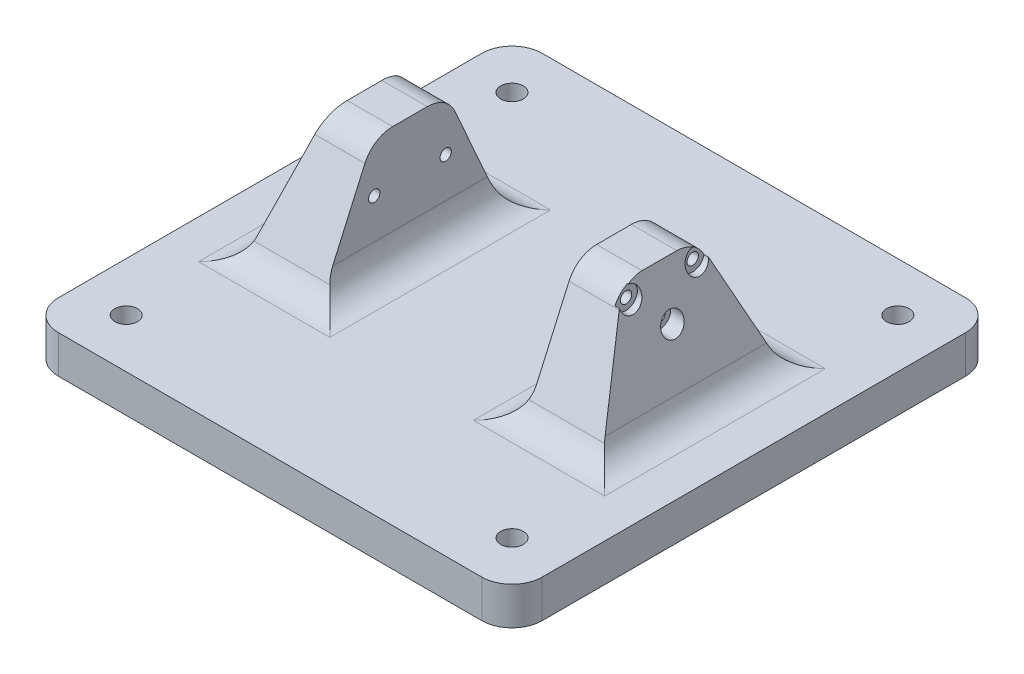
from build123d import *

# Parameters (mm, degrees)
SKETCH1_W           = 101.6
SKETCH1_H           = 101.6
BOSS_EXTRUDE1_DEPTH = 7.9375
BOSS_EXTRUDE2_DEPTH = 9.525
DRAFT2_ANGLE        = 15
DRAFT3_ANGLE        = 15
FILLET3_R           = 6.35
CUT_EXTRUDE1_REACH  = 31.369
SKETCH3_R           = 1.190625
SKETCH4_R           = 2.38125
CUT_EXTRUDE2_DEPTH  = 6.35
SKETCH5_R           = 2.38125
CUT_EXTRUDE3_DEPTH  = 7.9375
CUT_EXTRUDE4_REACH  = 31.369
SKETCH6_R           = 1.190625
CUT_EXTRUDE5_REACH  = 21.844
SKETCH7_R           = 2.38125
SKETCH7_R_2         = 1.190625
FILLET4_R           = 6.35


with BuildPart() as part:
    # Sketch1 → Boss-Extrude1 (new body)
    with BuildSketch(Plane(origin=(0, 0, 0), x_dir=(1, 0, 0), z_dir=(0, 1, 0))):
        with Locations((50.8, 50.8)):
            Rectangle(SKETCH1_W, SKETCH1_H)
    extrude(amount=BOSS_EXTRUDE1_DEPTH)

    # Sketch2 → Boss-Extrude2 (add)
    with BuildSketch(Plane.ZY.offset(-29.36875)):
        Polygon((-31.75, 7.9375), (-69.85, 7.9375), (-58.57875, 33.3375), (-43.02125, 33.3375), align=None)
    boss_extrude2 = extrude(amount=BOSS_EXTRUDE2_DEPTH)

    # Draft2
    draft2_faces = [part.faces().sort_by_distance(p)[0] for p in [
        (19.84375, 18.858999014, -50.8),
    ]]
    draft(draft2_faces, Plane(origin=(19.84375, 33.3375, -58.57875), x_dir=(0, 0, 1), z_dir=(0, 1, 0)), DRAFT2_ANGLE)

    # Mirror2: Boss-Extrude2 across plane
    add(boss_extrude2.mirror(Plane.ZY.offset(-50.8)))

    # Draft3
    draft3_faces = [part.faces().sort_by_distance(p)[0] for p in [
        (81.75625, 18.858999014, -50.8),
    ]]
    draft(draft3_faces, Plane(origin=(81.75625, 33.3375, -58.57875), x_dir=(0, 0, 1), z_dir=(0, 1, 0)), DRAFT3_ANGLE)

    # Fillet3
    fillet3_edges = [part.edges().sort_by_distance(p)[0] for p in [
        (21.203295256, 7.9375, -31.75),
        (24.60625, 33.3375, -43.02125),
        (24.60625, 33.3375, -58.57875),
        (29.36875, 7.9375, -50.8),
        (21.203295256, 7.9375, -69.85),
        (13.037840512, 7.9375, -50.8),
        (76.99375, 33.3375, -43.02125),
        (88.562159488, 7.9375, -50.8),
        (80.396704744, 7.9375, -31.75),
        (80.396704744, 7.9375, -69.85),
        (76.99375, 33.3375, -58.57875),
        (72.23125, 7.9375, -50.8),
    ]]
    fillet(fillet3_edges, radius=FILLET3_R)

    # Cut-Extrude1: up to this face of the body (flat: up to its plane)
    cut_extrude1_end = Plane(part.part.faces().sort_by_distance((84.905739541, 21.583445016, -50.8))[0])
    # Sketch3 → Cut-Extrude1 (cut, up to the picked face)
    with BuildSketch(Plane.ZY.offset(-72.23125), mode=Mode.PRIVATE) as cut_extrude1_sk1:
        with Locations((-57.8, 30.1625)):
            Circle(SKETCH3_R)
    cut_extrude1_tool1 = split(extrude(cut_extrude1_sk1.sketch, amount=-CUT_EXTRUDE1_REACH, mode=Mode.PRIVATE), bisect_by=cut_extrude1_end, keep=Keep.BOTH, mode=Mode.PRIVATE)
    add(cut_extrude1_tool1.solids().sort_by_distance((72.23125, 30.1625, -57.8))[0], mode=Mode.SUBTRACT)
    # Sketch3 → Cut-Extrude1 (cut, up to the picked face)
    with BuildSketch(Plane.ZY.offset(-72.23125), mode=Mode.PRIVATE) as cut_extrude1_sk2:
        with Locations((-43.8, 30.1625)):
            Circle(SKETCH3_R)
    cut_extrude1_tool2 = split(extrude(cut_extrude1_sk2.sketch, amount=-CUT_EXTRUDE1_REACH, mode=Mode.PRIVATE), bisect_by=cut_extrude1_end, keep=Keep.BOTH, mode=Mode.PRIVATE)
    add(cut_extrude1_tool2.solids().sort_by_distance((72.23125, 30.1625, -43.8))[0], mode=Mode.SUBTRACT)
    # Sketch3 → Cut-Extrude1 (cut, up to the picked face)
    with BuildSketch(Plane.ZY.offset(-72.23125), mode=Mode.PRIVATE) as cut_extrude1_sk3:
        with Locations((-50.8, 23.1625)):
            Circle(SKETCH3_R)
    cut_extrude1_tool3 = split(extrude(cut_extrude1_sk3.sketch, amount=-CUT_EXTRUDE1_REACH, mode=Mode.PRIVATE), bisect_by=cut_extrude1_end, keep=Keep.BOTH, mode=Mode.PRIVATE)
    add(cut_extrude1_tool3.solids().sort_by_distance((72.23125, 23.1625, -50.8))[0], mode=Mode.SUBTRACT)

    # Sketch4 → Cut-Extrude2 (cut)
    with BuildSketch(Plane.ZY.offset(-81.75625)):
        with Locations((-43.8, 30.1625)):
            Circle(SKETCH4_R)
        with Locations((-57.8, 30.1625)):
            Circle(SKETCH4_R)
        with Locations((-50.8, 23.1625)):
            Circle(SKETCH4_R)
    extrude(amount=-CUT_EXTRUDE2_DEPTH, mode=Mode.SUBTRACT)

    # Sketch5 → Cut-Extrude3 (cut)
    with BuildSketch(Plane(origin=(0, 7.9375, 0), x_dir=(1, 0, 0), z_dir=(0, 1, 0))):
        with Locations((10.287, 91.313)):
            Circle(SKETCH5_R)
        with Locations((10.287, 10.287)):
            Circle(SKETCH5_R)
        with Locations((91.313, 10.287)):
            Circle(SKETCH5_R)
        with Locations((91.313, 91.313)):
            Circle(SKETCH5_R)
    extrude(amount=-CUT_EXTRUDE3_DEPTH, mode=Mode.SUBTRACT)

    # Cut-Extrude4: up to this face of the body (flat: up to its plane)
    cut_extrude4_end = Plane(part.part.faces().sort_by_distance((16.694260459, 21.583445016, -50.8))[0])
    # Sketch6 → Cut-Extrude4 (cut, up to the picked face)
    with BuildSketch(Plane(origin=(29.36875, 0, 0), x_dir=(0, 0, -1), z_dir=(1, 0, 0)), mode=Mode.PRIVATE) as cut_extrude4_sk1:
        with Locations((43.3, 22.6625)):
            Circle(SKETCH6_R)
    cut_extrude4_tool1 = split(extrude(cut_extrude4_sk1.sketch, amount=-CUT_EXTRUDE4_REACH, mode=Mode.PRIVATE), bisect_by=cut_extrude4_end, keep=Keep.BOTH, mode=Mode.PRIVATE)
    add(cut_extrude4_tool1.solids().sort_by_distance((29.36875, 22.6625, -43.3))[0], mode=Mode.SUBTRACT)
    # Sketch6 → Cut-Extrude4 (cut, up to the picked face)
    with BuildSketch(Plane(origin=(29.36875, 0, 0), x_dir=(0, 0, -1), z_dir=(1, 0, 0)), mode=Mode.PRIVATE) as cut_extrude4_sk2:
        with Locations((58.3, 22.6625)):
            Circle(SKETCH6_R)
    cut_extrude4_tool2 = split(extrude(cut_extrude4_sk2.sketch, amount=-CUT_EXTRUDE4_REACH, mode=Mode.PRIVATE), bisect_by=cut_extrude4_end, keep=Keep.BOTH, mode=Mode.PRIVATE)
    add(cut_extrude4_tool2.solids().sort_by_distance((29.36875, 22.6625, -58.3))[0], mode=Mode.SUBTRACT)

    # Sketch7 → Cut-Extrude5 (cut, up to next)
    with BuildSketch(Plane(origin=(19.84375, 0, 0), x_dir=(0, 0, -1), z_dir=(1, 0, 0)), mode=Mode.PRIVATE) as cut_extrude5_sk1:
        with Locations((58.3, 22.6625)):
            Circle(SKETCH7_R)
        with Locations((58.3, 22.6625)):
            Circle(SKETCH7_R_2, mode=Mode.SUBTRACT)
    cut_extrude5_tool1 = extrude(cut_extrude5_sk1.sketch, amount=-CUT_EXTRUDE5_REACH, mode=Mode.PRIVATE) & part.part
    add(cut_extrude5_tool1.solids().sort_by_distance((19.84375, 22.6625, -55.986102))[0], mode=Mode.SUBTRACT)
    # Sketch7 → Cut-Extrude5 (cut, up to next)
    with BuildSketch(Plane(origin=(19.84375, 0, 0), x_dir=(0, 0, -1), z_dir=(1, 0, 0)), mode=Mode.PRIVATE) as cut_extrude5_sk2:
        with Locations((43.3, 22.6625)):
            Circle(SKETCH7_R)
        with Locations((43.3, 22.6625)):
            Circle(SKETCH7_R_2, mode=Mode.SUBTRACT)
    cut_extrude5_tool2 = extrude(cut_extrude5_sk2.sketch, amount=-CUT_EXTRUDE5_REACH, mode=Mode.PRIVATE) & part.part
    add(cut_extrude5_tool2.solids().sort_by_distance((19.84375, 22.6625, -40.986102))[0], mode=Mode.SUBTRACT)

    # Fillet4
    fillet4_edges = [part.edges().sort_by_distance(p)[0] for p in [
        (0, 3.96875, -101.6),
        (101.6, 3.96875, -101.6),
        (101.6, 3.96875, 0),
        (0, 3.96875, 0),
    ]]
    fillet(fillet4_edges, radius=FILLET4_R)


solid = part.part
